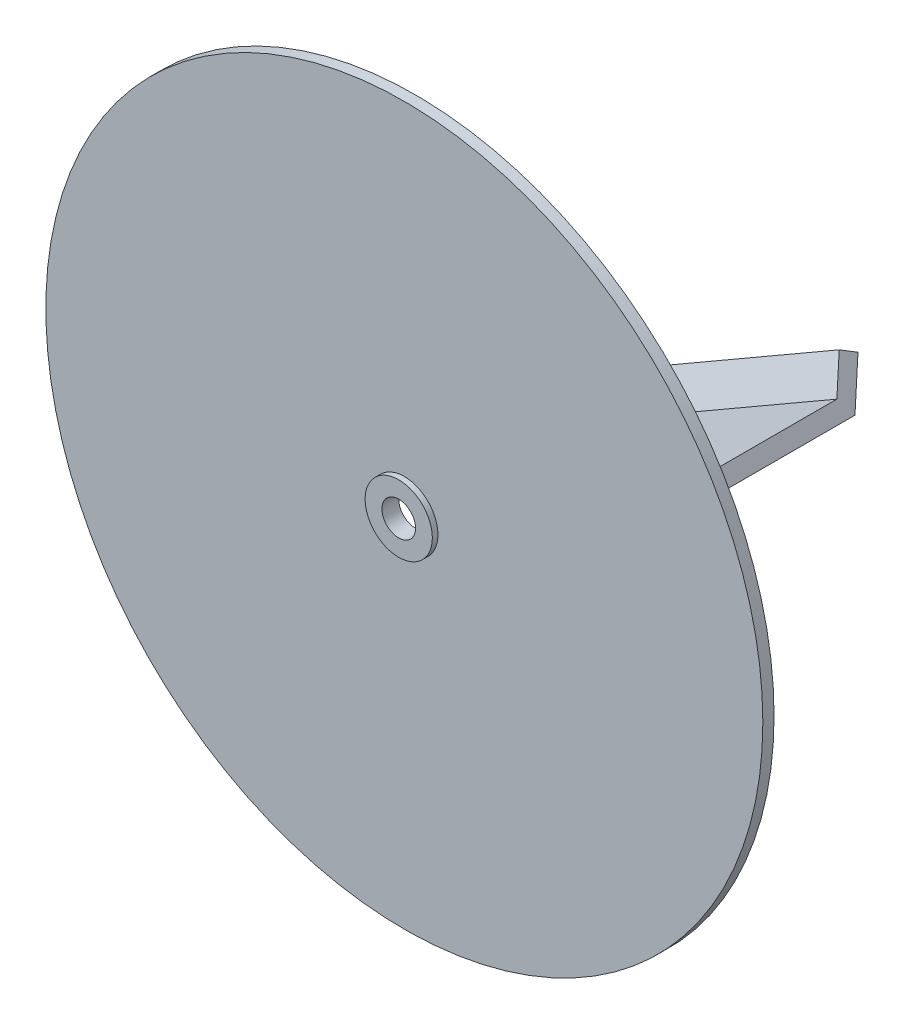
from build123d import *

# Parameters (mm, degrees)
SKETCH1_R           = 203.2
SKETCH1_R_2         = 9.525
BOSS_EXTRUDE1_DEPTH = 6.35
BOSS_EXTRUDE2_DEPTH = 171.45
CIRPATTERN1_COUNT   = 3
SKETCH3_R           = 19.05
SKETCH3_R_2         = 9.525
BOSS_EXTRUDE3_DEPTH = 3.175


with BuildPart() as part:
    # Sketch1 → Boss-Extrude1 (new body)
    with BuildSketch(Plane.XY):
        Circle(SKETCH1_R)
        Circle(SKETCH1_R_2, mode=Mode.SUBTRACT)
    extrude(amount=BOSS_EXTRUDE1_DEPTH)

    # Sketch2 → Boss-Extrude2 (add)
    with BuildSketch(Plane(origin=(0, -25.4, 0), x_dir=(1, 0, 0), z_dir=(0, 1, 0))):
        Polygon((-4.7625, 0), (-4.7625, 76.2), (17.234545256, 88.9), (21.997045256, 80.651108029), (4.7625, 70.700738686), (4.7625, 0), align=None)
    boss_extrude2 = extrude(amount=-BOSS_EXTRUDE2_DEPTH)

    # CirPattern1: Boss-Extrude2 ×3 about axis
    cirpattern1_axis = Axis((0, 0, 0), (0, 0, 1))
    for i in range(1, CIRPATTERN1_COUNT):
        add(boss_extrude2.rotate(cirpattern1_axis, i * 360 / CIRPATTERN1_COUNT))

    # Sketch3 → Boss-Extrude3 (add)
    with BuildSketch(Plane.XY.offset(6.35)):
        Circle(SKETCH3_R)
        Circle(SKETCH3_R_2, mode=Mode.SUBTRACT)
    extrude(amount=BOSS_EXTRUDE3_DEPTH)


solid = part.part
